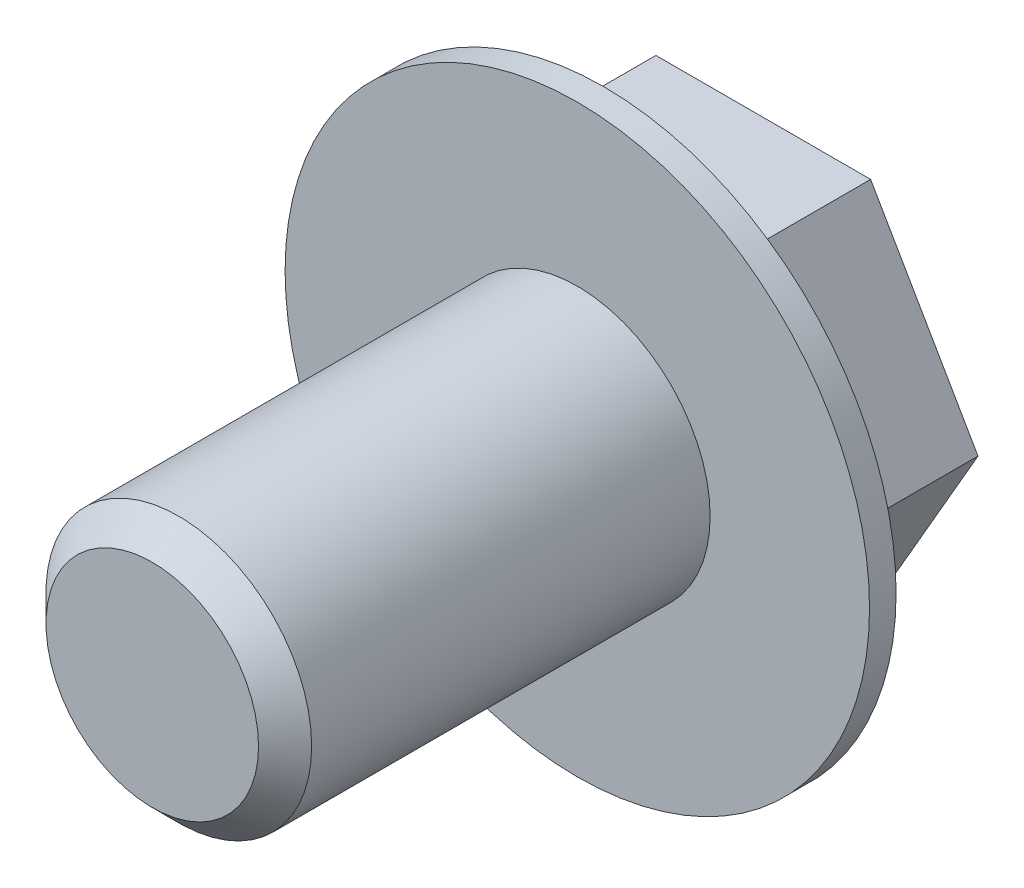
from build123d import *

# Parameters (mm, degrees)
SKETCH1_R           = 2.5
BOSS_EXTRUDE1_DEPTH = 8
SKETCH2_R           = 5.5
BOSS_EXTRUDE2_DEPTH = 0.5
BOSS_EXTRUDE3_DEPTH = 3
CHAMFER3_SIZE       = 0.5


with BuildPart() as part:
    # Sketch1 → Boss-Extrude1 (new body)
    with BuildSketch(Plane.XY):
        Circle(SKETCH1_R)
    extrude(amount=BOSS_EXTRUDE1_DEPTH)

    # Sketch2 → Boss-Extrude2 (add)
    with BuildSketch(Plane(origin=(0, 0, 0), x_dir=(-1, 0, 0), z_dir=(0, 0, -1))):
        Circle(SKETCH2_R)
    extrude(amount=BOSS_EXTRUDE2_DEPTH)

    # Sketch3 → Boss-Extrude3 (add)
    with BuildSketch(Plane(origin=(0, 0, -0.5), x_dir=(-1, 0, 0), z_dir=(0, 0, -1))):
        Polygon((4.041451884, 0), (2.020725942, 3.5), (-2.020725942, 3.5), (-4.041451884, 0), (-2.020725942, -3.5), (2.020725942, -3.5), align=None)
    extrude(amount=BOSS_EXTRUDE3_DEPTH)

    # Chamfer3
    chamfer3_edges = [part.edges().sort_by_distance(p)[0] for p in [
        (-2.5, 0, 8),
    ]]
    chamfer(chamfer3_edges, length=CHAMFER3_SIZE)


solid = part.part
